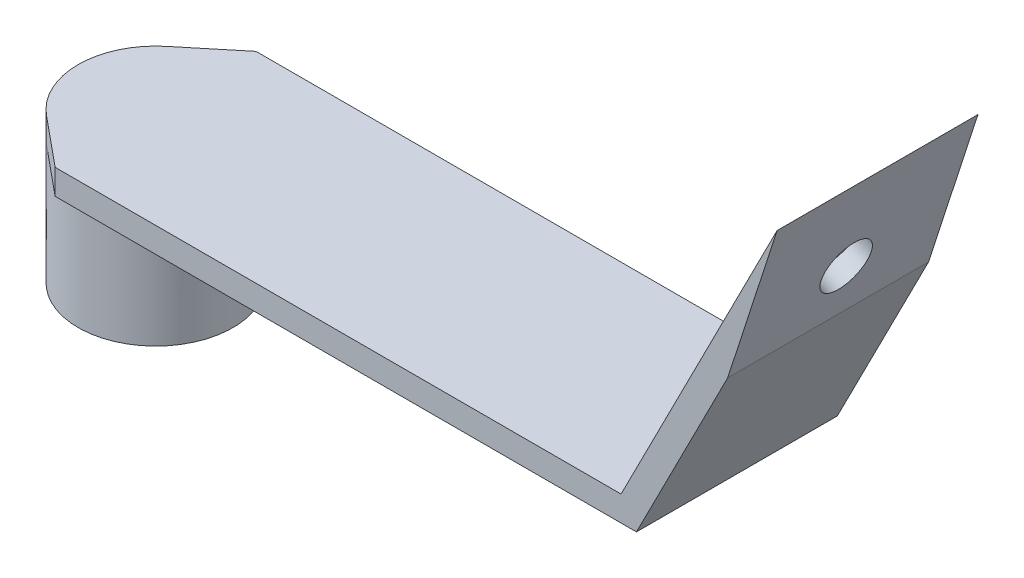
from build123d import *

# Parameters (mm, degrees)
BOSS_EXTRUDE1_DEPTH = 25.4
SKETCH2_R           = 9.801448676
SKETCH2_R_2         = 7.071368029
BOSS_EXTRUDE2_DEPTH = 19
BOSS_EXTRUDE3_DEPTH = 3.175
SKETCH4_R           = 3.175
CUT_EXTRUDE1_DEPTH  = 3.175


with BuildPart() as part:
    # Sketch1 → Boss-Extrude1 (new body)
    with BuildSketch(Plane.XY):
        Polygon((-92.495819173, -3.422180745), (-20.941461675, -3.422180745), (-1.20885062, 35.305249012), (-7.464460479, 16.03438497), (-18.995819173, -6.597180745), (-92.495819173, -6.597180745), align=None)
    extrude(amount=BOSS_EXTRUDE1_DEPTH)

    # Sketch2 → Boss-Extrude2 (add)
    with BuildSketch(Plane(origin=(0, -3.422180745, 0), x_dir=(1, 0, 0), z_dir=(0, 1, 0))):
        with Locations((-92.495819173, -12.7)):
            Circle(SKETCH2_R)
        with Locations((-92.495819173, -12.7)):
            Circle(SKETCH2_R_2, mode=Mode.SUBTRACT)
    extrude(amount=-BOSS_EXTRUDE2_DEPTH)

    # Sketch3 → Boss-Extrude3 (add)
    with BuildSketch(Plane(origin=(0, -3.422180745, 0), x_dir=(1, 0, 0), z_dir=(0, 1, 0))):
        with BuildLine():
            Line((-98.728601618, -16.040159995), (-98.728601618, -9.359840005))
            ThreePointArc((-98.728601618, -9.359840005), (-99.567187202, -12.7), (-98.728601618, -16.040159995))
        make_face()
        with BuildLine():
            Line((-98.728601618, -9.359840005), (-98.728601618, -5.135555597))
            Line((-98.728601618, -5.135555597), (-102.297267848, -12.7))
            Line((-102.297267848, -12.7), (-98.728601618, -20.264444403))
            Line((-98.728601618, -20.264444403), (-98.728601618, -16.040159995))
            ThreePointArc((-98.728601618, -16.040159995), (-99.567187202, -12.7), (-98.728601618, -9.359840005))
        make_face()
        with BuildLine():
            ThreePointArc((-92.495819173, -2.898551324), (-95.806852438, -3.474738223), (-98.728601618, -5.135555597))
            Line((-98.728601618, -5.135555597), (-98.728601618, -9.359840005))
            ThreePointArc((-98.728601618, -9.359840005), (-96.12794976, -6.632721104), (-92.495819173, -5.628631971))
            Line((-92.495819173, -5.628631971), (-92.495819173, -2.898551324))
        make_face()
        with BuildLine():
            ThreePointArc((-92.495819173, -19.771368029), (-96.12794976, -18.767278896), (-98.728601618, -16.040159995))
            Line((-98.728601618, -16.040159995), (-98.728601618, -20.264444403))
            ThreePointArc((-98.728601618, -20.264444403), (-95.806852438, -21.925261777), (-92.495819173, -22.501448676))
            Line((-92.495819173, -22.501448676), (-92.495819173, -19.771368029))
        make_face()
        with BuildLine():
            ThreePointArc((-92.495819173, -22.501448676), (-95.806852438, -21.925261777), (-98.728601618, -20.264444403))
            Line((-98.728601618, -20.264444403), (-92.495819173, -25.4))
            Line((-92.495819173, -25.4), (-92.495819173, -22.501448676))
        make_face()
        with BuildLine():
            ThreePointArc((-92.495819173, -5.628631971), (-96.12794976, -6.632721104), (-98.728601618, -9.359840005))
            Line((-98.728601618, -9.359840005), (-98.728601618, -16.040159995))
            ThreePointArc((-98.728601618, -16.040159995), (-96.12794976, -18.767278896), (-92.495819173, -19.771368029))
            Line((-92.495819173, -19.771368029), (-92.495819173, -5.628631971))
        make_face()
        with BuildLine():
            Line((-92.495819173, -2.898551324), (-92.495819173, 0))
            Line((-92.495819173, 0), (-98.728601618, -5.135555597))
            ThreePointArc((-98.728601618, -5.135555597), (-95.806852438, -3.474738223), (-92.495819173, -2.898551324))
        make_face()
    extrude(amount=-BOSS_EXTRUDE3_DEPTH)

    # Sketch4 → Cut-Extrude1 (cut)
    with BuildSketch(Plane(origin=(-15.240970814, 7.765662505, 0), x_dir=(0, 0, 1), z_dir=(-0.891006524, 0.4539905, 0))):
        with Locations((12.7, 18.20840051)):
            Circle(SKETCH4_R)
    extrude(amount=-CUT_EXTRUDE1_DEPTH, mode=Mode.SUBTRACT)


solid = part.part
